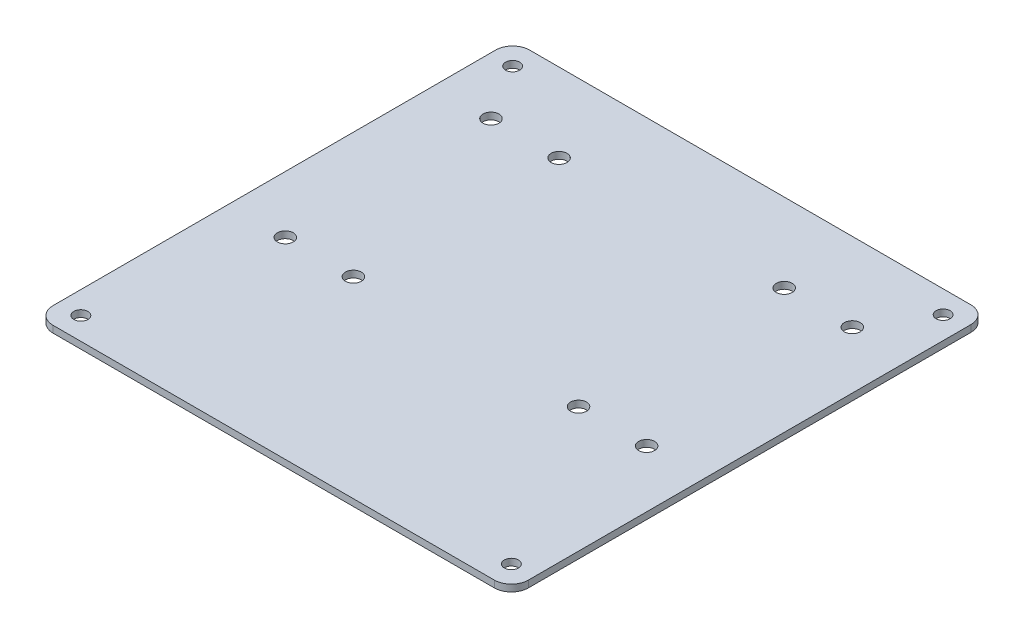
from build123d import *

# Parameters (mm, degrees)
SKETCH1_W           = 111.7
SKETCH1_H           = 112
SKETCH1_R           = 1.65
SKETCH1_R_2         = 1.875
BOSS_EXTRUDE1_DEPTH = 1.6
FILLET1_R           = 4


with BuildPart() as part:
    # Sketch1 → Boss-Extrude1 (new body)
    with BuildSketch(Plane(origin=(0, 0, 0), x_dir=(1, 0, 0), z_dir=(0, 1, 0))):
        Rectangle(SKETCH1_W, SKETCH1_H)
        with Locations((-50.575, 50.725)):
            Circle(SKETCH1_R, mode=Mode.SUBTRACT)
        with Locations((-50.575, -50.725)):
            Circle(SKETCH1_R, mode=Mode.SUBTRACT)
        with Locations((50.575, 50.725)):
            Circle(SKETCH1_R, mode=Mode.SUBTRACT)
        with Locations((50.575, -50.725)):
            Circle(SKETCH1_R, mode=Mode.SUBTRACT)
        with Locations((26.45, -10.82)):
            Circle(SKETCH1_R_2, mode=Mode.SUBTRACT)
        with Locations((42.45, -10.82)):
            Circle(SKETCH1_R_2, mode=Mode.SUBTRACT)
        with Locations((42.45, 37.51)):
            Circle(SKETCH1_R_2, mode=Mode.SUBTRACT)
        with Locations((26.45, 37.51)):
            Circle(SKETCH1_R_2, mode=Mode.SUBTRACT)
        with Locations((-42.45, -10.82)):
            Circle(SKETCH1_R_2, mode=Mode.SUBTRACT)
        with Locations((-26.45, -10.82)):
            Circle(SKETCH1_R_2, mode=Mode.SUBTRACT)
        with Locations((-42.45, 37.51)):
            Circle(SKETCH1_R_2, mode=Mode.SUBTRACT)
        with Locations((-26.45, 37.51)):
            Circle(SKETCH1_R_2, mode=Mode.SUBTRACT)
    extrude(amount=BOSS_EXTRUDE1_DEPTH)

    # Fillet1
    fillet1_edges = [part.edges().sort_by_distance(p)[0] for p in [
        (55.85, 0.8, 56),
        (-55.85, 0.8, 56),
        (-55.85, 0.8, -56),
        (55.85, 0.8, -56),
    ]]
    fillet(fillet1_edges, radius=FILLET1_R)


solid = part.part
